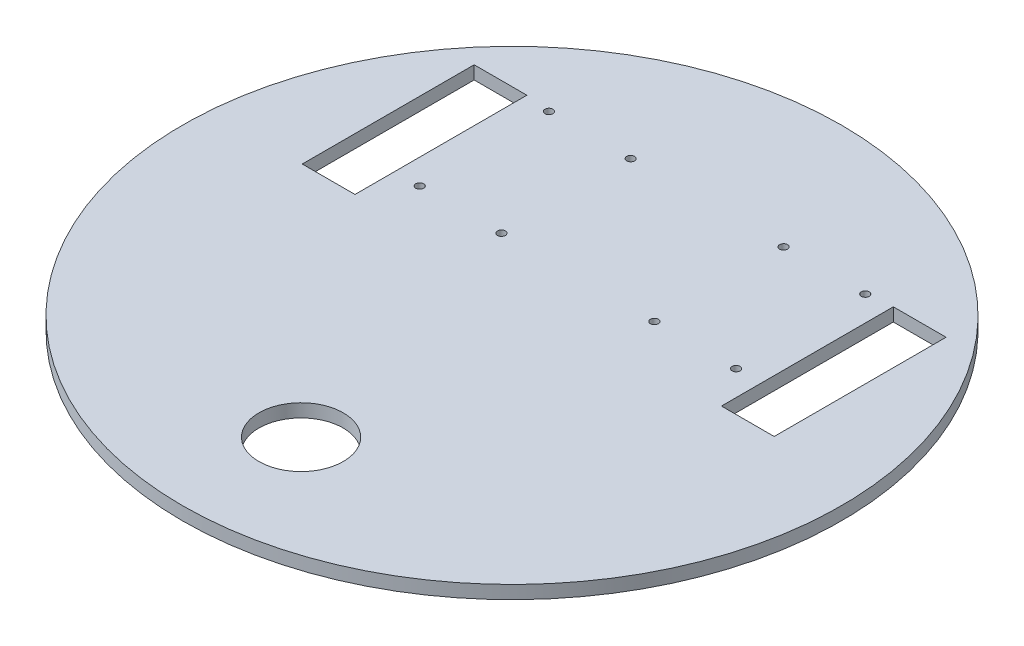
from build123d import *

# Parameters (mm, degrees)
SKETCH1_R           = 125
SKETCH1_R_2         = 16
SKETCH1_R_3         = 1.5
SKETCH1_W           = 20
SKETCH1_H           = 65.2
BOSS_EXTRUDE1_DEPTH = 5


with BuildPart() as part:
    # Sketch1 → Boss-Extrude1 (new body)
    with BuildSketch(Plane(origin=(0, 0, 0), x_dir=(1, 0, 0), z_dir=(0, 1, 0))):
        with Locations((0, -6.988561475)):
            Circle(SKETCH1_R)
        with Locations((0, -86.988561475)):
            Circle(SKETCH1_R_2, mode=Mode.SUBTRACT)
        with Locations((60, 18.011438525)):
            Circle(SKETCH1_R_3, mode=Mode.SUBTRACT)
        with Locations((60, 67.011438525)):
            Circle(SKETCH1_R_3, mode=Mode.SUBTRACT)
        with Locations((29, 67.011438525)):
            Circle(SKETCH1_R_3, mode=Mode.SUBTRACT)
        with Locations((29, 18.011438525)):
            Circle(SKETCH1_R_3, mode=Mode.SUBTRACT)
        with Locations((-60, 18.011438525)):
            Circle(SKETCH1_R_3, mode=Mode.SUBTRACT)
        with Locations((-29, 18.011438525)):
            Circle(SKETCH1_R_3, mode=Mode.SUBTRACT)
        with Locations((-29, 67.011438525)):
            Circle(SKETCH1_R_3, mode=Mode.SUBTRACT)
        with Locations((-60, 67.011438525)):
            Circle(SKETCH1_R_3, mode=Mode.SUBTRACT)
        with Locations((79.5, 35.555700821)):
            Rectangle(SKETCH1_W, SKETCH1_H, mode=Mode.SUBTRACT)
        with Locations((-79.5, 35.555700821)):
            Rectangle(SKETCH1_W, SKETCH1_H, mode=Mode.SUBTRACT)
    extrude(amount=BOSS_EXTRUDE1_DEPTH)


solid = part.part
